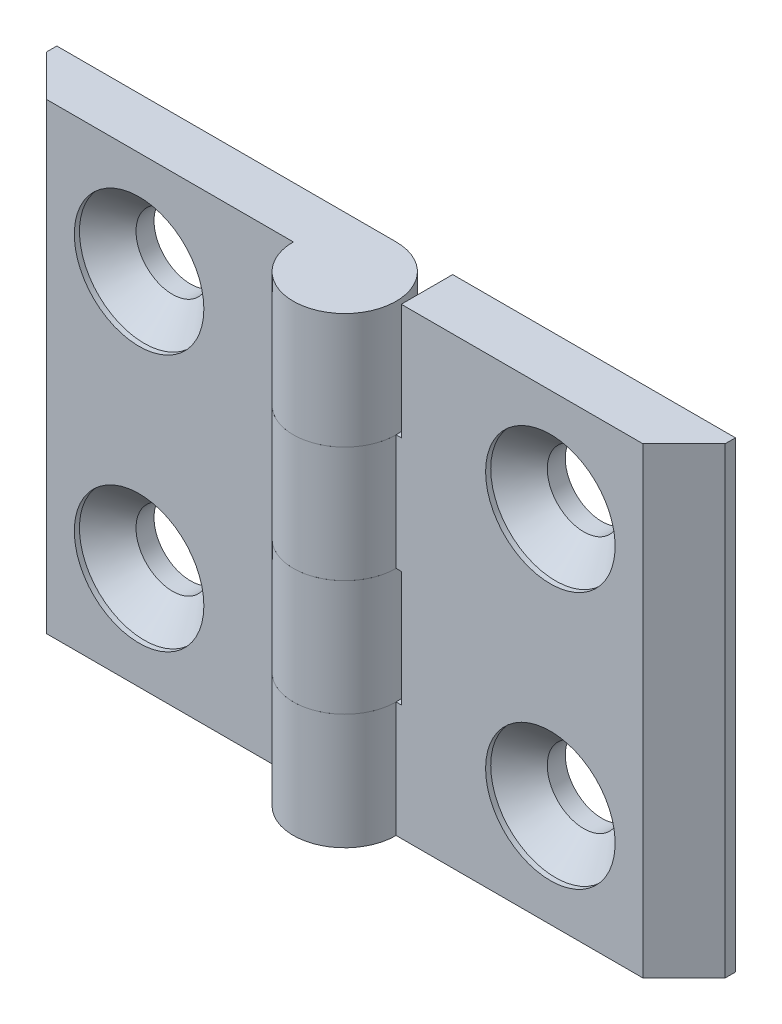
from build123d import *

# Parameters (mm, degrees)
EXTRUDE_1_DEPTH            = 22.5
SKETCH_3_W                 = 10.5
SKETCH_3_H                 = 11.25
CUT_EXTRUDE_1_DEPTH        = 6
CUT_EXTRUDE_1_DEPTH_BACK   = 6
HOLE_WIZARD_M61_AT_2_COUNT = 2
HOLE_WIZARD_M61_AT_2_PITCH = 25
PATTERN_CIRCULAR_1_COUNT   = 2


with BuildPart() as part:
    # Эскиз1 → Бобышка-Вытянуть1 (new body, symmetric)
    with BuildSketch(Plane(origin=(0, 0, 0), x_dir=(1, 0, 0), z_dir=(0, 1, 0))):
        with BuildLine():
            Line((0, 5), (-33, 5))
            Line((-33, 5), (-33, 4))
            Line((-33, 4), (-29, 0))
            Line((-29, 0), (-5, 0))
            ThreePointArc((-5, 0), (3.535533906, -3.535533906), (0, 5))
        make_face()
    extrude(amount=EXTRUDE_1_DEPTH, both=True)

    # Эскиз3 → Вырез-Вытянуть1 (cut, two sides)
    with BuildSketch(Plane.XY) as cut_extrude_1_sk:
        with Locations((-0.25, 5.625)):
            Rectangle(SKETCH_3_W, SKETCH_3_H)
        with Locations((-0.25, -16.875)):
            Rectangle(SKETCH_3_W, SKETCH_3_H)
    extrude(amount=CUT_EXTRUDE_1_DEPTH, mode=Mode.SUBTRACT)
    extrude(cut_extrude_1_sk.sketch, amount=-CUT_EXTRUDE_1_DEPTH_BACK, mode=Mode.SUBTRACT)

    # Эскиз6 → Зенковка для винта с полупотайной головкой M61 (revolve, cut)
    with BuildSketch(Plane(origin=(-20, 12.5, 0), x_dir=(0, -1, 0), z_dir=(1, 0, 0))):
        Polygon((0, 0), (0, 5), (3.55, 5), (3.55, 3.25), (6.3, 0.5), (6.3, 0), align=None)
    hole_wizard_m61 = revolve(axis=Axis((-20, 12.5, 6.35), (0, 0, -1)), mode=Mode.SUBTRACT)

    # Зенковка для винта с полупотайной головкой M61 at 2: Зенковка для винта с полупотайной головкой M61 ×2
    with Locations(*[(0, -i * HOLE_WIZARD_M61_AT_2_PITCH, 0) for i in range(1, HOLE_WIZARD_M61_AT_2_COUNT)]):
        add(hole_wizard_m61, mode=Mode.SUBTRACT)


with BuildPart() as pattern_circular_1_1:
    # Круговой массив1: pattern copy
    add(part.part.rotate(Axis((0, 0, 0), (0, 0, 1)), 1 * 360 / PATTERN_CIRCULAR_1_COUNT))


solid = Compound([part.part, pattern_circular_1_1.part])
